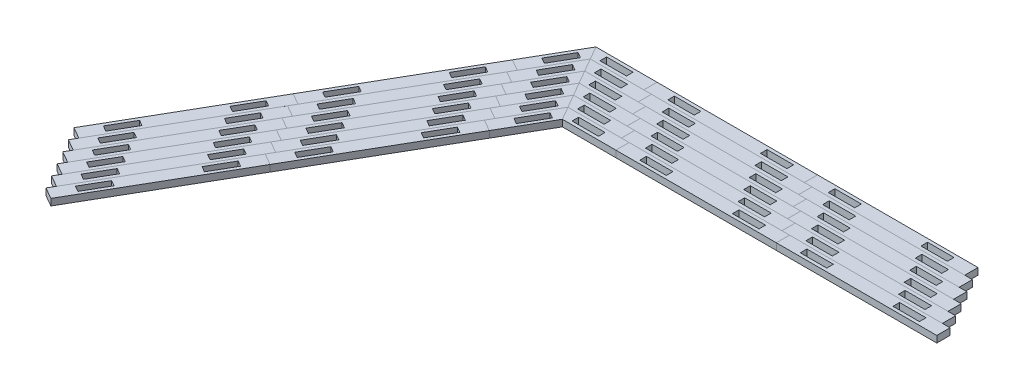
from build123d import *

# Parameters (mm, degrees)
BOSS_EXTRUDE1_DEPTH = 6.35
CUT_EXTRUDE4_DEPTH  = 155.110195964
BOSS_EXTRUDE4_DEPTH = 6.35
CIRPATTERN1_COUNT   = 2
CIRPATTERN1_ANGLE   = 60
SKETCH12_W          = 153.979316792
SKETCH12_H          = 120.65
CUT_EXTRUDE5_DEPTH  = 155.110195964
SKETCH13_W          = 25.4
SKETCH13_H          = 6.35
CUT_EXTRUDE6_DEPTH  = 90.126497182
LPATTERN1_COUNT     = 5
LPATTERN1_PITCH     = 153.979316882
LPATTERN1_2_COUNT   = 2
LPATTERN1_2_PITCH   = 153.979316882
SKETCH14_W          = 25.4
SKETCH14_H          = 6.35
CUT_EXTRUDE7_DEPTH  = 695.360232872
CUT_EXTRUDE8_DEPTH  = 600.270912242
LPATTERN2_COUNT     = 6
LPATTERN2_PITCH     = 14.664696858


with BuildPart() as part:
    # Sketch1 → Boss-Extrude1 (new body)
    with BuildSketch(Plane(origin=(0, 0, 0), x_dir=(1, 0, 0), z_dir=(0, 1, 0))):
        Polygon((-76.989658396, 0), (0, -44.45), (76.989658396, 0), (76.989658396, 88.9), (0, 133.35), (-76.989658396, 88.9), align=None)
    extrude(amount=-BOSS_EXTRUDE1_DEPTH)

    # Sketch10 → Cut-Extrude4 (cut, through all)
    with BuildSketch(Plane(origin=(0, 0, 0), x_dir=(1, 0, 0), z_dir=(0, 1, 0))):
        Polygon((-21.997045256, -31.75), (-13.322783942, -29.425738686), (-35.319829198, -16.725738686), (-38.494829198, -22.225), align=None)
    cut_extrude4 = extrude(amount=-CUT_EXTRUDE4_DEPTH, mode=Mode.SUBTRACT)

    # Sketch11 → Boss-Extrude4 (add)
    with BuildSketch(Plane(origin=(0, 0, 0), x_dir=(1, 0, 0), z_dir=(0, 1, 0))):
        Polygon((-38.494829198, -22.225), (-41.669829198, -27.724261314), (-63.666874454, -15.024261314), (-54.99261314, -12.7), align=None)
    boss_extrude4 = extrude(amount=-BOSS_EXTRUDE4_DEPTH)

    # CirPattern1: Cut-Extrude4, Boss-Extrude4 ×2 about axis
    cirpattern1_axis = Axis((0, 0, -44.45), (0, 1, 0))
    add([cut_extrude4.rotate(cirpattern1_axis, i * CIRPATTERN1_ANGLE / (CIRPATTERN1_COUNT - 1)) for i in range(1, CIRPATTERN1_COUNT)], mode=Mode.SUBTRACT)
    add([boss_extrude4.rotate(cirpattern1_axis, i * CIRPATTERN1_ANGLE / (CIRPATTERN1_COUNT - 1)) for i in range(1, CIRPATTERN1_COUNT)])

    # Sketch12 → Cut-Extrude5 (cut, through all)
    with BuildSketch(Plane(origin=(0, 0, 0), x_dir=(1, 0, 0), z_dir=(0, 1, 0))):
        with Locations((0, 73.025)):
            Rectangle(SKETCH12_W, SKETCH12_H)
    extrude(amount=-CUT_EXTRUDE5_DEPTH, mode=Mode.SUBTRACT)

    # Sketch13 → Cut-Extrude6 (cut, through all)
    with BuildSketch(Plane(origin=(0, 0, 0), x_dir=(1, 0, 0), z_dir=(0, 1, 0))):
        with Locations((-44.45, 6.35)):
            Rectangle(SKETCH13_W, SKETCH13_H)
        with Locations((44.45, 6.35)):
            Rectangle(SKETCH13_W, SKETCH13_H)
    extrude(amount=-CUT_EXTRUDE6_DEPTH, mode=Mode.SUBTRACT)


with BuildPart() as lpattern1_1:
    # LPattern1: pattern copy
    add(part.part.moved(Location(Vector(1, 0, 0) * (1 * LPATTERN1_PITCH))))


with BuildPart() as lpattern1_2:
    # LPattern1: pattern copy
    add(part.part.moved(Location(Vector(1, 0, 0) * (2 * LPATTERN1_PITCH))))


with BuildPart() as lpattern1_3:
    # LPattern1: pattern copy
    add(part.part.moved(Location(Vector(1, 0, 0) * (3 * LPATTERN1_PITCH))))


with BuildPart() as lpattern1_4:
    # LPattern1: pattern copy
    add(part.part.moved(Location(Vector(1, 0, 0) * (4 * LPATTERN1_PITCH))))


with BuildPart() as lpattern1_2_1:
    # LPattern1 2: pattern copy
    add(part.part.moved(Location(Vector(-1, 0, 0) * (1 * LPATTERN1_2_PITCH))))


with BuildPart() as cut_extrude7_tool:
    # Sketch14 → Cut-Extrude7 (new, through all)
    # profile 1 of 2: a face of its own
    with BuildSketch(Plane(origin=(0, 0, 0), x_dir=(1, 0, 0), z_dir=(0, 1, 0))):
        Polygon((593.920222272, -31.75), (615.917267528, -44.45), (637.914312784, -31.75), (635.59005147, -40.424261314), (657.587096726, -27.724261314), (651.237096726, -16.725738686), (673.234141982, -4.025738686), (670.909880668, -12.7), (692.906925924, 0), (692.906925924, 12.7), (597.586396481, 12.7), (580.59743833, -16.725738686), (602.594483586, -29.425738686), align=None)
        with Locations((660.367267528, 6.35)):
            Rectangle(SKETCH14_W, SKETCH14_H, mode=Mode.SUBTRACT)
    # profile 2 of 2: a face of its own
    with BuildSketch(Plane(origin=(0, 0, 0), x_dir=(1, 0, 0), z_dir=(0, 1, 0))):
        Polygon((-230.968975278, -44.45), (-153.979316882, -44.45), (-134.30653294, -40.424261314), (-112.309487684, -27.724261314), (-135.648445835, 12.7), (-230.968975278, 12.7), align=None)
    extrude(amount=-CUT_EXTRUDE7_DEPTH)


with BuildPart() as lpattern1_4_1:
    add(lpattern1_4.part)

    # Cut-Extrude7: cut by cut_extrude7_tool
    add(cut_extrude7_tool.part, mode=Mode.SUBTRACT)


with BuildPart() as lpattern1_2_1_1:
    add(lpattern1_2_1.part)

    # Cut-Extrude7: cut by cut_extrude7_tool
    add(cut_extrude7_tool.part, mode=Mode.SUBTRACT)


with BuildPart() as cut_extrude8_tool:
    # Sketch15 → Cut-Extrude8 (new, through all)
    with BuildSketch(Plane(origin=(0, 0, 0), x_dir=(1, 0, 0), z_dir=(0, 1, 0))):
        Polygon((-156.381024632, 0), (-156.381024632, -63.5), (618.318975368, -63.5), (618.318975368, 12.7), (230.968975368, 12.7), (230.968975368, 0), align=None)
    extrude(amount=-CUT_EXTRUDE8_DEPTH)


with BuildPart() as part_1:
    add(part.part)

    # Cut-Extrude8: cut by cut_extrude8_tool
    add(cut_extrude8_tool.part, mode=Mode.SUBTRACT)


with BuildPart() as lpattern1_1_1:
    add(lpattern1_1.part)

    # Cut-Extrude8: cut by cut_extrude8_tool
    add(cut_extrude8_tool.part, mode=Mode.SUBTRACT)


with BuildPart() as lpattern1_2_2:
    add(lpattern1_2.part)

    # Cut-Extrude8: cut by cut_extrude8_tool
    add(cut_extrude8_tool.part, mode=Mode.SUBTRACT)


with BuildPart() as lpattern1_3_1:
    add(lpattern1_3.part)

    # Cut-Extrude8: cut by cut_extrude8_tool
    add(cut_extrude8_tool.part, mode=Mode.SUBTRACT)


with BuildPart() as lpattern1_4_2:
    add(lpattern1_4_1.part)

    # Cut-Extrude8: cut by cut_extrude8_tool
    add(cut_extrude8_tool.part, mode=Mode.SUBTRACT)


with BuildPart() as lpattern1_2_1_2:
    add(lpattern1_2_1_1.part)

    # Cut-Extrude8: cut by cut_extrude8_tool
    add(cut_extrude8_tool.part, mode=Mode.SUBTRACT)


with BuildPart() as body_4:
    # Mirror1: mirrored copy
    add(lpattern1_2_1_2.part.mirror(Plane(origin=(-96.237073062, -6.35, 55.562500039), x_dir=(0.4999999999999999, 0, 0.8660254037844387), z_dir=(0.8660254037844387, 0, -0.4999999999999999))))


with BuildPart() as body_5:
    # Mirror1 2: mirrored copy
    add(part_1.part.mirror(Plane(origin=(-96.237073062, -6.35, 55.562500039), x_dir=(0.4999999999999999, 0, 0.8660254037844387), z_dir=(0.8660254037844387, 0, -0.4999999999999999))))


with BuildPart() as body_6:
    # Mirror1 3: mirrored copy
    add(lpattern1_1_1.part.mirror(Plane(origin=(-96.237073062, -6.35, 55.562500039), x_dir=(0.4999999999999999, 0, 0.8660254037844387), z_dir=(0.8660254037844387, 0, -0.4999999999999999))))


with BuildPart() as lpattern2_1:
    # LPattern2: pattern copy
    add(body_6.part.moved(Location(Vector(0.49999999999999994, 0, 0.8660254037844387) * (1 * LPATTERN2_PITCH))))


with BuildPart() as lpattern2_2:
    # LPattern2: pattern copy
    add(body_6.part.moved(Location(Vector(0.49999999999999994, 0, 0.8660254037844387) * (2 * LPATTERN2_PITCH))))


with BuildPart() as lpattern2_3:
    # LPattern2: pattern copy
    add(body_6.part.moved(Location(Vector(0.49999999999999994, 0, 0.8660254037844387) * (3 * LPATTERN2_PITCH))))


with BuildPart() as lpattern2_4:
    # LPattern2: pattern copy
    add(body_6.part.moved(Location(Vector(0.49999999999999994, 0, 0.8660254037844387) * (4 * LPATTERN2_PITCH))))


with BuildPart() as lpattern2_5:
    # LPattern2: pattern copy
    add(body_6.part.moved(Location(Vector(0.49999999999999994, 0, 0.8660254037844387) * (5 * LPATTERN2_PITCH))))


with BuildPart() as lpattern2_6:
    # LPattern2: pattern copy
    add(lpattern1_2_1_2.part.moved(Location(Vector(0.49999999999999994, 0, 0.8660254037844387) * (1 * LPATTERN2_PITCH))))


with BuildPart() as lpattern2_7:
    # LPattern2: pattern copy
    add(lpattern1_2_1_2.part.moved(Location(Vector(0.49999999999999994, 0, 0.8660254037844387) * (2 * LPATTERN2_PITCH))))


with BuildPart() as lpattern2_8:
    # LPattern2: pattern copy
    add(lpattern1_2_1_2.part.moved(Location(Vector(0.49999999999999994, 0, 0.8660254037844387) * (3 * LPATTERN2_PITCH))))


with BuildPart() as lpattern2_9:
    # LPattern2: pattern copy
    add(lpattern1_2_1_2.part.moved(Location(Vector(0.49999999999999994, 0, 0.8660254037844387) * (4 * LPATTERN2_PITCH))))


with BuildPart() as lpattern2_10:
    # LPattern2: pattern copy
    add(lpattern1_2_1_2.part.moved(Location(Vector(0.49999999999999994, 0, 0.8660254037844387) * (5 * LPATTERN2_PITCH))))


with BuildPart() as lpattern2_11:
    # LPattern2: pattern copy
    add(lpattern1_1_1.part.moved(Location(Vector(0.49999999999999994, 0, 0.8660254037844387) * (1 * LPATTERN2_PITCH))))


with BuildPart() as lpattern2_12:
    # LPattern2: pattern copy
    add(lpattern1_1_1.part.moved(Location(Vector(0.49999999999999994, 0, 0.8660254037844387) * (2 * LPATTERN2_PITCH))))


with BuildPart() as lpattern2_13:
    # LPattern2: pattern copy
    add(lpattern1_1_1.part.moved(Location(Vector(0.49999999999999994, 0, 0.8660254037844387) * (3 * LPATTERN2_PITCH))))


with BuildPart() as lpattern2_14:
    # LPattern2: pattern copy
    add(lpattern1_1_1.part.moved(Location(Vector(0.49999999999999994, 0, 0.8660254037844387) * (4 * LPATTERN2_PITCH))))


with BuildPart() as lpattern2_15:
    # LPattern2: pattern copy
    add(lpattern1_1_1.part.moved(Location(Vector(0.49999999999999994, 0, 0.8660254037844387) * (5 * LPATTERN2_PITCH))))


with BuildPart() as lpattern2_16:
    # LPattern2: pattern copy
    add(part_1.part.moved(Location(Vector(0.49999999999999994, 0, 0.8660254037844387) * (1 * LPATTERN2_PITCH))))


with BuildPart() as lpattern2_17:
    # LPattern2: pattern copy
    add(part_1.part.moved(Location(Vector(0.49999999999999994, 0, 0.8660254037844387) * (2 * LPATTERN2_PITCH))))


with BuildPart() as lpattern2_18:
    # LPattern2: pattern copy
    add(part_1.part.moved(Location(Vector(0.49999999999999994, 0, 0.8660254037844387) * (3 * LPATTERN2_PITCH))))


with BuildPart() as lpattern2_19:
    # LPattern2: pattern copy
    add(part_1.part.moved(Location(Vector(0.49999999999999994, 0, 0.8660254037844387) * (4 * LPATTERN2_PITCH))))


with BuildPart() as lpattern2_20:
    # LPattern2: pattern copy
    add(part_1.part.moved(Location(Vector(0.49999999999999994, 0, 0.8660254037844387) * (5 * LPATTERN2_PITCH))))


with BuildPart() as lpattern2_21:
    # LPattern2: pattern copy
    add(body_4.part.moved(Location(Vector(0.49999999999999994, 0, 0.8660254037844387) * (1 * LPATTERN2_PITCH))))


with BuildPart() as lpattern2_22:
    # LPattern2: pattern copy
    add(body_4.part.moved(Location(Vector(0.49999999999999994, 0, 0.8660254037844387) * (2 * LPATTERN2_PITCH))))


with BuildPart() as lpattern2_23:
    # LPattern2: pattern copy
    add(body_4.part.moved(Location(Vector(0.49999999999999994, 0, 0.8660254037844387) * (3 * LPATTERN2_PITCH))))


with BuildPart() as lpattern2_24:
    # LPattern2: pattern copy
    add(body_4.part.moved(Location(Vector(0.49999999999999994, 0, 0.8660254037844387) * (4 * LPATTERN2_PITCH))))


with BuildPart() as lpattern2_25:
    # LPattern2: pattern copy
    add(body_4.part.moved(Location(Vector(0.49999999999999994, 0, 0.8660254037844387) * (5 * LPATTERN2_PITCH))))


with BuildPart() as lpattern2_26:
    # LPattern2: pattern copy
    add(body_5.part.moved(Location(Vector(0.49999999999999994, 0, 0.8660254037844387) * (1 * LPATTERN2_PITCH))))


with BuildPart() as lpattern2_27:
    # LPattern2: pattern copy
    add(body_5.part.moved(Location(Vector(0.49999999999999994, 0, 0.8660254037844387) * (2 * LPATTERN2_PITCH))))


with BuildPart() as lpattern2_28:
    # LPattern2: pattern copy
    add(body_5.part.moved(Location(Vector(0.49999999999999994, 0, 0.8660254037844387) * (3 * LPATTERN2_PITCH))))


with BuildPart() as lpattern2_29:
    # LPattern2: pattern copy
    add(body_5.part.moved(Location(Vector(0.49999999999999994, 0, 0.8660254037844387) * (4 * LPATTERN2_PITCH))))


with BuildPart() as lpattern2_30:
    # LPattern2: pattern copy
    add(body_5.part.moved(Location(Vector(0.49999999999999994, 0, 0.8660254037844387) * (5 * LPATTERN2_PITCH))))


solid = Compound([part_1.part, lpattern1_1_1.part, lpattern1_2_1_2.part, body_4.part, body_5.part, body_6.part, lpattern2_1.part, lpattern2_2.part, lpattern2_3.part, lpattern2_4.part, lpattern2_5.part, lpattern2_6.part, lpattern2_7.part, lpattern2_8.part, lpattern2_9.part, lpattern2_10.part, lpattern2_11.part, lpattern2_12.part, lpattern2_13.part, lpattern2_14.part, lpattern2_15.part, lpattern2_16.part, lpattern2_17.part, lpattern2_18.part, lpattern2_19.part, lpattern2_20.part, lpattern2_21.part, lpattern2_22.part, lpattern2_23.part, lpattern2_24.part, lpattern2_25.part, lpattern2_26.part, lpattern2_27.part, lpattern2_28.part, lpattern2_29.part, lpattern2_30.part])
